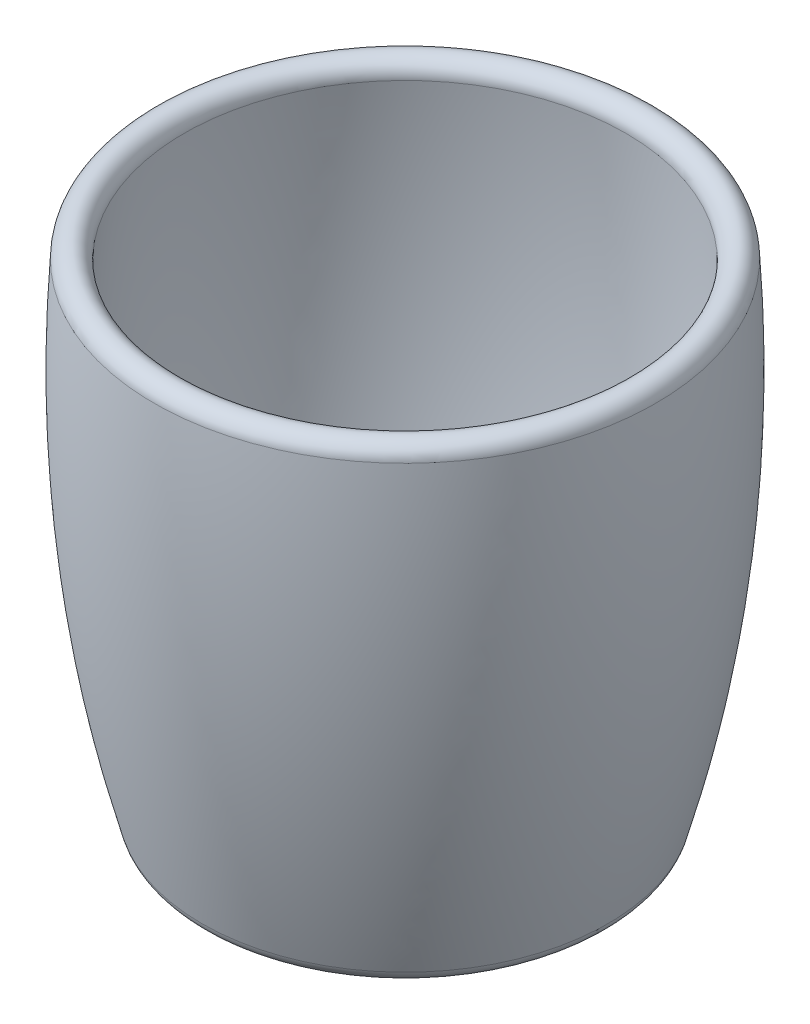
from build123d import *

# Parameters (mm, degrees)
FILLET1_R = 3


with BuildPart() as part:
    # Sketch1 → Revolve1 (revolve)
    with BuildSketch(Plane.XY):
        with BuildLine():
            Line((0, 0), (33.25, 0))
            add(Edge.make_bspline(
                [(33.25, 0), (40.770585082, 26.227397042), (43.637251749, 53.360730375), (41.85, 81.4)],
                knots=[0, 0, 0, 0, 1, 1, 1, 1], degree=3))
            ThreePointArc((41.85, 81.4), (39.1960334, 83.735906952), (36.860126448, 81.081940352))
            add(Edge.make_bspline(
                [(29.450423152, 5), (31.098721331, 11.122731195), (33.890065025, 23.513467046), (36.51627774, 42.362705396), (37.414431967, 58.346354897), (37.357321389, 71.274458443), (37.067836742, 77.823280829), (36.860126448, 81.081940352)],
                knots=[0.046951369, 0.046951369, 0.046951369, 0.046951369, 0.285213527, 0.523475685, 0.761737842, 0.880868921, 1, 1, 1, 1], degree=3))
            Line((29.450423152, 5), (0, 5))
            Line((0, 5), (0, 0))
        make_face()
    revolve(axis=Axis((0, 0, 0), (0, 1, 0)))

    # Fillet1
    fillet1_edges = [part.edges().sort_by_distance(p)[0] for p in [
        (-33.25, 0, 0),
        (-29.450423152, 5, 0),
    ]]
    fillet(fillet1_edges, radius=FILLET1_R)


solid = part.part
